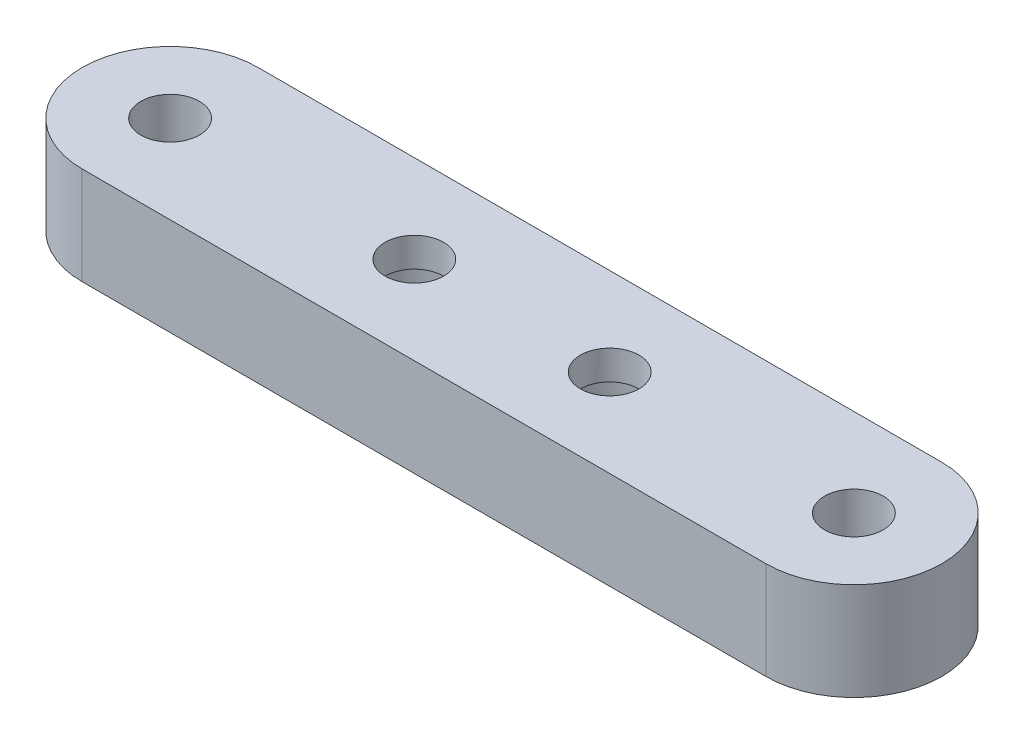
from build123d import *

# Parameters (mm, degrees)
SKETCH2_R           = 3
BOSS_EXTRUDE1_DEPTH = 10
SKETCH3_R           = 5
CUT_EXTRUDE1_DEPTH  = 7


with BuildPart() as part:
    # Sketch2 → Boss-Extrude1 (new body)
    with BuildSketch(Plane(origin=(0, 0, 0), x_dir=(1, 0, 0), z_dir=(0, 1, 0))):
        with BuildLine():
            ThreePointArc((25, -9), (34, 0), (25, 9))
            Line((25, 9), (-45, 9))
            ThreePointArc((-45, 9), (-54, 0), (-45, -9))
            Line((-45, -9), (25, -9))
        make_face()
        with Locations((-20, 0)):
            Circle(SKETCH2_R, mode=Mode.SUBTRACT)
        Circle(SKETCH2_R, mode=Mode.SUBTRACT)
        with Locations((25, 0)):
            Circle(SKETCH2_R, mode=Mode.SUBTRACT)
        with Locations((-45, 0)):
            Circle(SKETCH2_R, mode=Mode.SUBTRACT)
    extrude(amount=BOSS_EXTRUDE1_DEPTH)

    # Sketch3 → Cut-Extrude1 (cut)
    with BuildSketch(Plane.XZ):
        with Locations((-20, 0)):
            Circle(SKETCH3_R)
        Circle(SKETCH3_R)
    extrude(amount=-CUT_EXTRUDE1_DEPTH, mode=Mode.SUBTRACT)


solid = part.part
